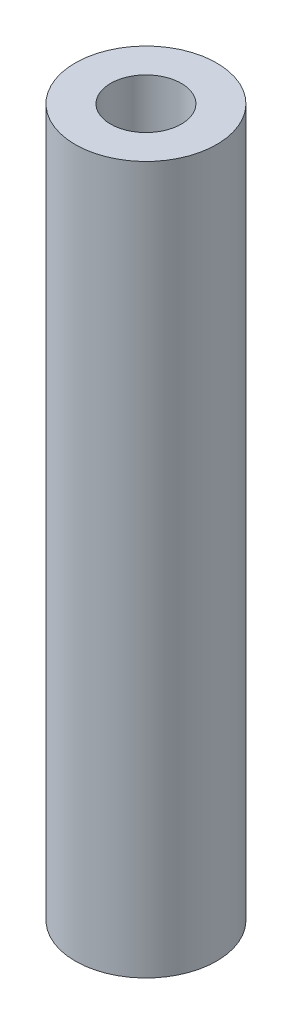
from build123d import *

# Parameters (mm, degrees)
SKETCH1_R           = 3.175
SKETCH1_R_2         = 1.5875
BOSS_EXTRUDE1_DEPTH = 31.75


with BuildPart() as part:
    # Sketch1 → Boss-Extrude1 (new body)
    with BuildSketch(Plane(origin=(0, 0, 0), x_dir=(1, 0, 0), z_dir=(0, 1, 0))):
        Circle(SKETCH1_R)
        Circle(SKETCH1_R_2, mode=Mode.SUBTRACT)
    extrude(amount=BOSS_EXTRUDE1_DEPTH)


solid = part.part
